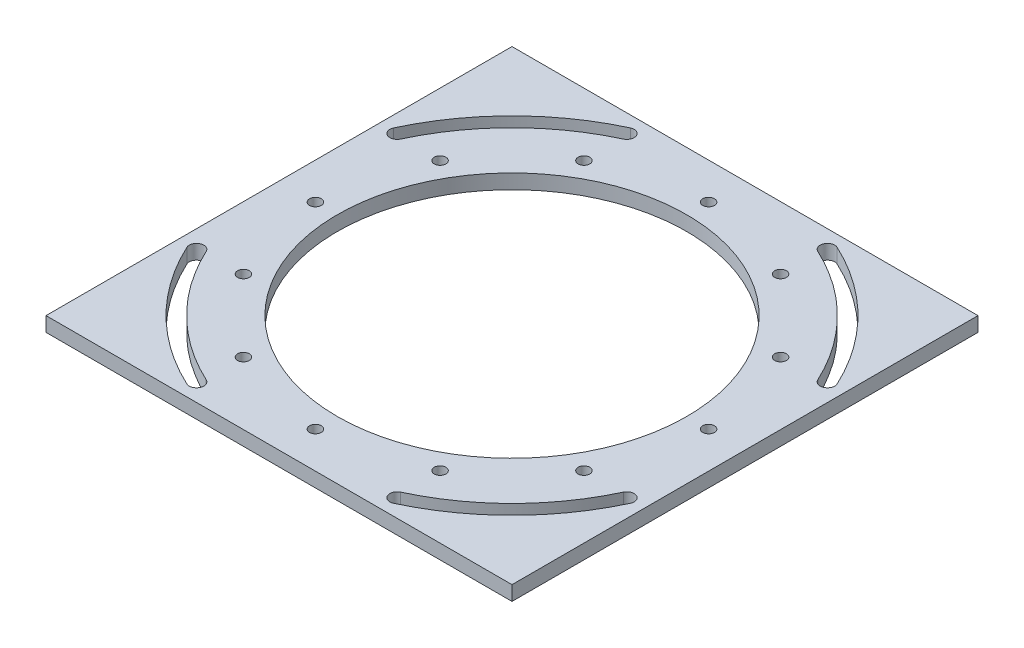
from build123d import *

# Parameters (mm, degrees)
SKETCH1_W                   = 203.2
SKETCH1_H                   = 203.2
BOSS_EXTRUDE1_DEPTH         = 6.35
CUT_EXTRUDE1_REACH          = 8.35
SKETCH2_R                   = 76.2
F_1_4_20_TAPPED_HOLE1_D     = 5.1054
F_1_4_20_TAPPED_HOLE1_DEPTH = 6.351
CIRPATTERN1_COUNT           = 12
CUT_EXTRUDE2_REACH          = 8.35


with BuildPart() as part:
    # Sketch1 → Boss-Extrude1 (new body)
    with BuildSketch(Plane(origin=(0, 0, 0), x_dir=(1, 0, 0), z_dir=(0, 1, 0))):
        Rectangle(SKETCH1_W, SKETCH1_H)
    extrude(amount=BOSS_EXTRUDE1_DEPTH)

    # Sketch2 → Cut-Extrude1 (cut, up to next)
    with BuildSketch(Plane(origin=(0, 6.35, 0), x_dir=(1, 0, 0), z_dir=(0, 1, 0)), mode=Mode.PRIVATE) as cut_extrude1_sk1:
        with Locations(Location((0, 0, 0), (0, 0, 270))):  # turned: the seam where the file's is
            Circle(SKETCH2_R)
    cut_extrude1_tool1 = extrude(cut_extrude1_sk1.sketch, amount=-CUT_EXTRUDE1_REACH, mode=Mode.PRIVATE) & part.part
    add(cut_extrude1_tool1.solids().sort_by_distance((0, 6.35, 0))[0], mode=Mode.SUBTRACT)

    # 1/4-20 Tapped Hole1
    with Locations(Plane(origin=(0, 6.35, 0), x_dir=(1, 0, 0), z_dir=(0, 1, 0))):
        with Locations((0, 85.725)):
            f_1_4_20_tapped_hole1 = Hole(F_1_4_20_TAPPED_HOLE1_D / 2, depth=F_1_4_20_TAPPED_HOLE1_DEPTH)

    # CirPattern1: 1/4-20 Tapped Hole1 ×12 about axis
    cirpattern1_axis = Axis((0, 0, 0), (0, 1, 0))
    for i in range(1, CIRPATTERN1_COUNT):
        add(f_1_4_20_tapped_hole1.rotate(cirpattern1_axis, i * 360 / CIRPATTERN1_COUNT), mode=Mode.SUBTRACT)

    # Sketch5 → Cut-Extrude2 (cut, up to next)
    with BuildSketch(Plane(origin=(0, 6.35, 0), x_dir=(1, 0, 0), z_dir=(0, 1, 0)), mode=Mode.PRIVATE) as cut_extrude2_sk1:
        with BuildLine():
            ThreePointArc((-45.084916162, 96.684914721), (-75.434151417, 75.434151417), (-96.684914721, 45.084916162))
            ThreePointArc((-96.684914721, 45.084916162), (-95.149200478, 40.865575958), (-90.929860273, 42.4012902))
            ThreePointArc((-90.929860273, 42.4012902), (-70.944023356, 70.944023356), (-42.4012902, 90.929860273))
            ThreePointArc((-42.4012902, 90.929860273), (-40.865575958, 95.149200478), (-45.084916162, 96.684914721))
        make_face()
    cut_extrude2_tool1 = extrude(cut_extrude2_sk1.sketch, amount=-CUT_EXTRUDE2_REACH, mode=Mode.PRIVATE) & part.part
    add(cut_extrude2_tool1.solids().sort_by_distance((-71.522214, 6.35, -71.522214))[0], mode=Mode.SUBTRACT)
    # Sketch5 → Cut-Extrude2 (cut, up to next)
    with BuildSketch(Plane(origin=(0, 6.35, 0), x_dir=(1, 0, 0), z_dir=(0, 1, 0)), mode=Mode.PRIVATE) as cut_extrude2_sk2:
        with BuildLine():
            ThreePointArc((96.684914721, 45.084916162), (75.434151417, 75.434151417), (45.084916162, 96.684914721))
            ThreePointArc((45.084916162, 96.684914721), (40.865575958, 95.149200478), (42.4012902, 90.929860273))
            ThreePointArc((42.4012902, 90.929860273), (70.944023356, 70.944023356), (90.929860273, 42.4012902))
            ThreePointArc((90.929860273, 42.4012902), (95.149200478, 40.865575958), (96.684914721, 45.084916162))
        make_face()
    cut_extrude2_tool2 = extrude(cut_extrude2_sk2.sketch, amount=-CUT_EXTRUDE2_REACH, mode=Mode.PRIVATE) & part.part
    add(cut_extrude2_tool2.solids().sort_by_distance((71.522214, 6.35, -71.522214))[0], mode=Mode.SUBTRACT)
    # Sketch5 → Cut-Extrude2 (cut, up to next)
    with BuildSketch(Plane(origin=(0, 6.35, 0), x_dir=(1, 0, 0), z_dir=(0, 1, 0)), mode=Mode.PRIVATE) as cut_extrude2_sk3:
        with BuildLine():
            ThreePointArc((-96.684914721, -45.084916162), (-75.434151417, -75.434151417), (-45.084916162, -96.684914721))
            ThreePointArc((-45.084916162, -96.684914721), (-40.865575958, -95.149200478), (-42.4012902, -90.929860273))
            ThreePointArc((-42.4012902, -90.929860273), (-70.944023356, -70.944023356), (-90.929860273, -42.4012902))
            ThreePointArc((-90.929860273, -42.4012902), (-95.149200478, -40.865575958), (-96.684914721, -45.084916162))
        make_face()
    cut_extrude2_tool3 = extrude(cut_extrude2_sk3.sketch, amount=-CUT_EXTRUDE2_REACH, mode=Mode.PRIVATE) & part.part
    add(cut_extrude2_tool3.solids().sort_by_distance((-71.522214, 6.35, 71.522214))[0], mode=Mode.SUBTRACT)
    # Sketch5 → Cut-Extrude2 (cut, up to next)
    with BuildSketch(Plane(origin=(0, 6.35, 0), x_dir=(1, 0, 0), z_dir=(0, 1, 0)), mode=Mode.PRIVATE) as cut_extrude2_sk4:
        with BuildLine():
            ThreePointArc((45.084916162, -96.684914721), (75.434151417, -75.434151417), (96.684914721, -45.084916162))
            ThreePointArc((96.684914721, -45.084916162), (95.149200478, -40.865575958), (90.929860273, -42.4012902))
            ThreePointArc((90.929860273, -42.4012902), (70.944023356, -70.944023356), (42.4012902, -90.929860273))
            ThreePointArc((42.4012902, -90.929860273), (40.865575958, -95.149200478), (45.084916162, -96.684914721))
        make_face()
    cut_extrude2_tool4 = extrude(cut_extrude2_sk4.sketch, amount=-CUT_EXTRUDE2_REACH, mode=Mode.PRIVATE) & part.part
    add(cut_extrude2_tool4.solids().sort_by_distance((71.522214, 6.35, 71.522214))[0], mode=Mode.SUBTRACT)


solid = part.part
